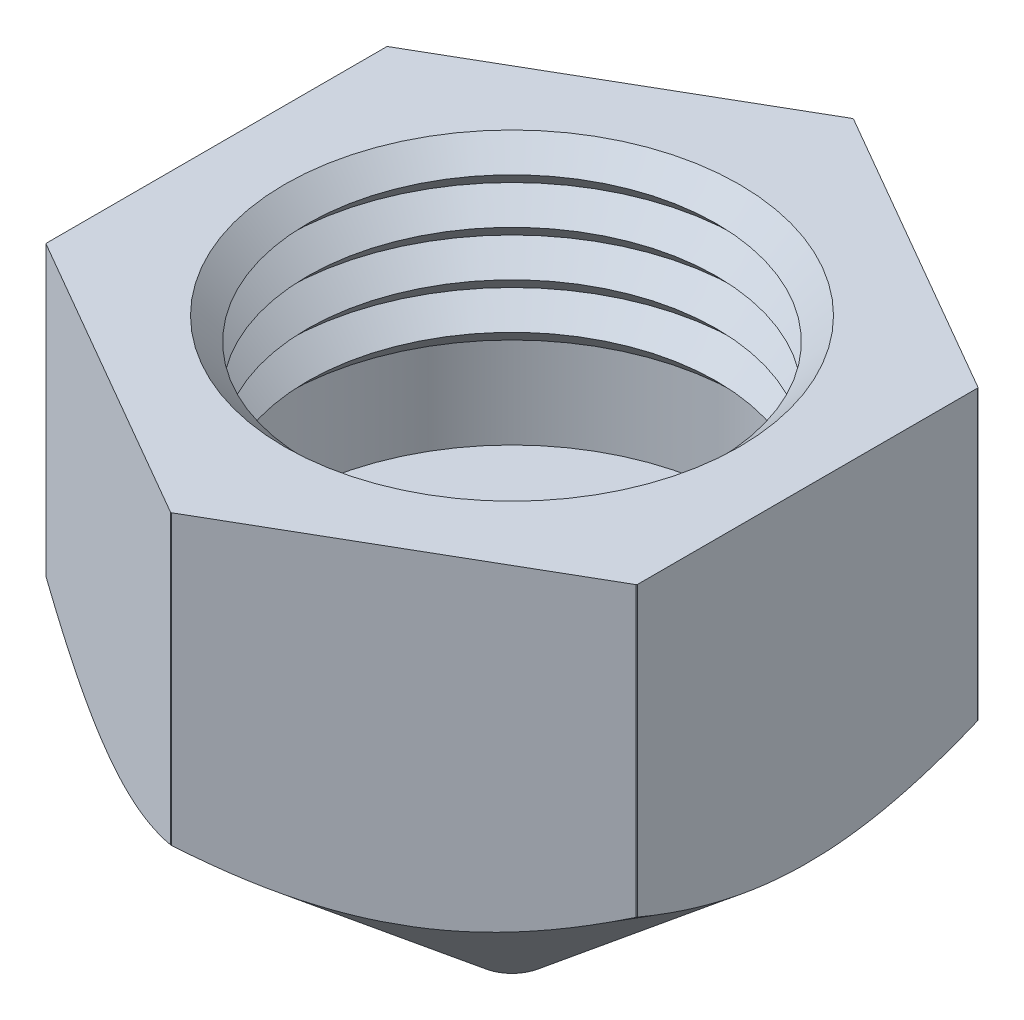
from build123d import *

# Parameters (mm, degrees)
SKETCH2_OUTSIDE_W  = 21.874
SKETCH2_OUTSIDE_H  = 21.874
CUT_EXTRUDE1_DEPTH = 13


with BuildPart() as part:
    # Sketch1 → Revolve1 (revolve)
    with BuildSketch(Plane.XY, mode=Mode.PRIVATE) as revolve1_sk:
        Polygon((0.25, -12), (0.75, -12), (7.5, -6.33607749), (7.5, 0), (5, 0), (4.5, -0.5), (5, -1), (4.5, -1.5), (5, -2), (4.5, -2.5), (5, -3), (4.5, -3.5), (5, -4), (5, -6), (2.0875, -6), (1.5875, -6.5), (1.5875, -9.90602957), (0.25, -11.5), align=None)
    revolve(revolve1_sk.sketch.rotate(Axis((0, 0, 0), (0, -1, 0)), 90), axis=Axis((0, 0, 0), (0, -1, 0)))  # turned: the seam where the file's is

    # Sketch2 outside → Cut-Extrude1 (cut, through all)
    with BuildSketch(Plane(origin=(0, 0, 0), x_dir=(1, 0, 0), z_dir=(0, 1, 0))):
        Rectangle(SKETCH2_OUTSIDE_W, SKETCH2_OUTSIDE_H)
        Polygon((0, 7.505553499), (-6.5, 3.75277675), (-6.5, -3.75277675), (0, -7.505553499), (6.5, -3.75277675), (6.5, 3.75277675), align=None, mode=Mode.SUBTRACT)
    extrude(amount=-CUT_EXTRUDE1_DEPTH, mode=Mode.SUBTRACT)


solid = part.part
